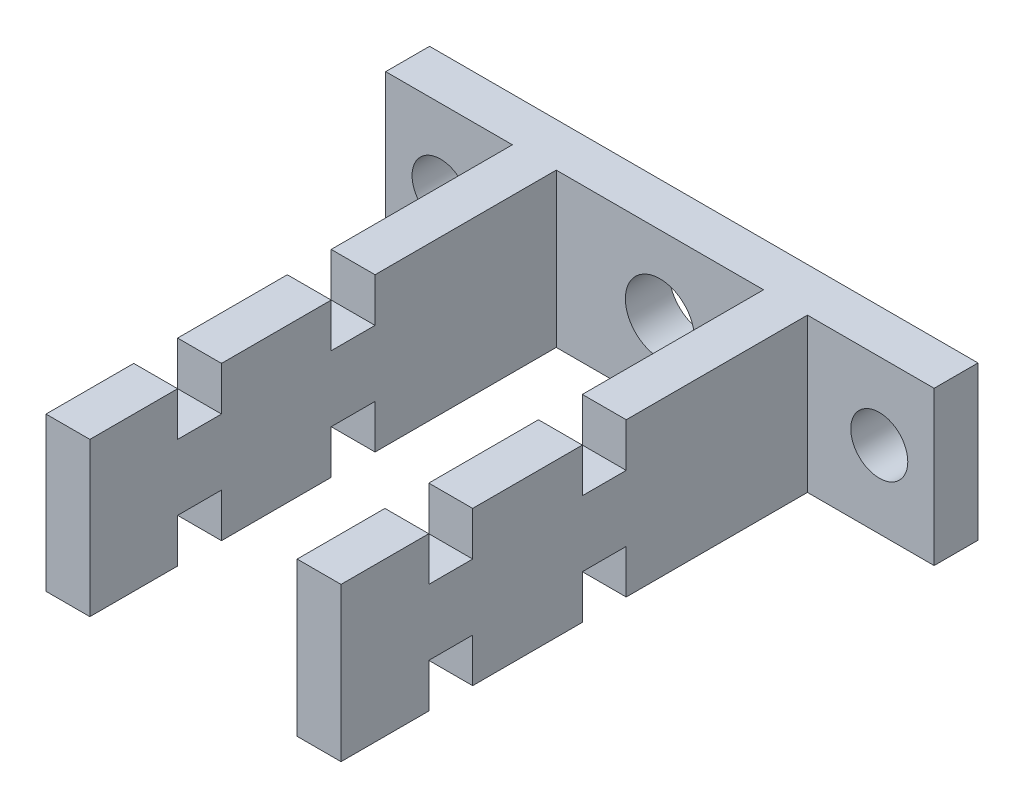
from build123d import *

# Parameters (mm, degrees)
SKETCH1_W                   = 31.75
SKETCH1_H                   = 8.89
SKETCH1_R                   = 2
BOSS_EXTRUDE1_DEPTH         = 2.54
SKETCH3_W                   = 2.54
SKETCH3_H                   = 8.89
BOSS_EXTRUDE2_DEPTH         = 27
SKETCH4_W                   = 17.08
SKETCH4_H                   = 2.54
CUT_EXTRUDE1_DEPTH          = 2.54
TAP_DRILL_FOR_M4X0_7_TAP1_D = 3.3


with BuildPart() as part:
    # Sketch1 → Boss-Extrude1 (new body)
    with BuildSketch(Plane.XY):
        with Locations((17.5, 25)):
            Rectangle(SKETCH1_W, SKETCH1_H)
        with Locations((17.5, 25)):
            Circle(SKETCH1_R, mode=Mode.SUBTRACT)
    extrude(amount=BOSS_EXTRUDE1_DEPTH)

    # Sketch3 → Boss-Extrude2 (add)
    with BuildSketch(Plane.XY.offset(2.54)):
        with Locations((10.23, 25)):
            Rectangle(SKETCH3_W, SKETCH3_H)
        with Locations((24.77, 25)):
            Rectangle(SKETCH3_W, SKETCH3_H)
    extrude(amount=BOSS_EXTRUDE2_DEPTH)

    # Sketch4 → Cut-Extrude1 (cut)
    with BuildSketch(Plane(origin=(0, 29.445, 0), x_dir=(1, 0, 0), z_dir=(0, 1, 0))):
        with Locations((17.5, -23.19)):
            Rectangle(SKETCH4_W, SKETCH4_H)
        with Locations((17.5, -14.3)):
            Rectangle(SKETCH4_W, SKETCH4_H)
    cut_extrude1 = extrude(amount=-CUT_EXTRUDE1_DEPTH, mode=Mode.SUBTRACT)

    # Mirror1: Cut-Extrude1 across plane
    add(cut_extrude1.mirror(Plane.ZX.offset(25)), mode=Mode.SUBTRACT)

    # Tap Drill for M4x0.7 Tap1 (through all)
    with Locations(Plane.XY.offset(2.54)):
        with Locations((4.8, 25), (30.2, 25)):
            Hole(TAP_DRILL_FOR_M4X0_7_TAP1_D / 2)


solid = part.part
